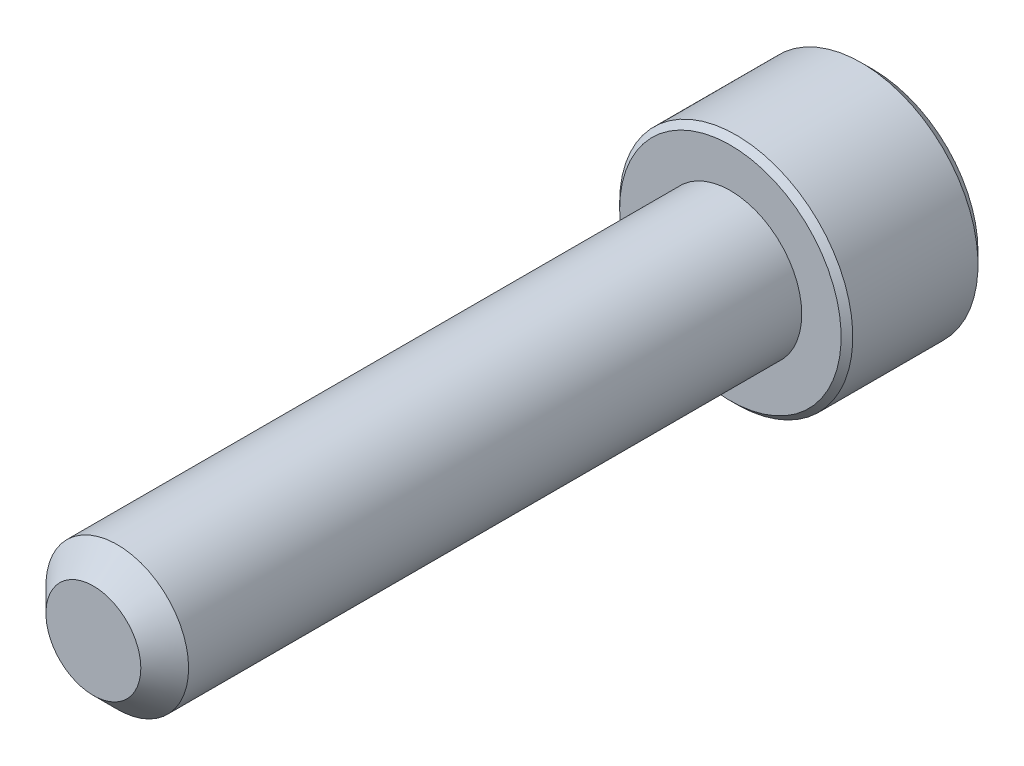
from build123d import *

# Parameters (mm, degrees)
SKETCH1_R          = 1.4224
EXTRUDE1_DEPTH     = 12.7
CHAMFER3_SIZE      = 0.47625
SKETCH6_R          = 2.3241
EXTRUDE2_DEPTH     = 2.8448
CUT_EXTRUDE1_DEPTH = 1.7859375
CHAMFER1_SIZE      = 0.23241
CHAMFER2_SIZE      = 0.116205


with BuildPart() as part:
    # Sketch1 → Extrude1 (new body)
    with BuildSketch(Plane.XY):
        Circle(SKETCH1_R)
    extrude(amount=-EXTRUDE1_DEPTH)

    # Chamfer3
    chamfer3_edges = [part.edges().sort_by_distance(p)[0] for p in [
        (-1.4224, 0, 0),
    ]]
    chamfer(chamfer3_edges, length=CHAMFER3_SIZE)

    # Sketch6 → Extrude2 (add)
    with BuildSketch(Plane(origin=(0, 0, -12.7), x_dir=(-1, 0, 0), z_dir=(0, 0, -1))):
        Circle(SKETCH6_R)
    extrude(amount=EXTRUDE2_DEPTH)

    # Sketch7 → Cut-Extrude1 (cut)
    with BuildSketch(Plane(origin=(0, 0, -15.5448), x_dir=(-1, 0, 0), z_dir=(0, 0, -1))):
        Polygon((0, 1.374815329), (-1.190625, 0.687407664), (-1.190625, -0.687407664), (0, -1.374815329), (1.190625, -0.687407664), (1.190625, 0.687407664), align=None)
    extrude(amount=-CUT_EXTRUDE1_DEPTH, mode=Mode.SUBTRACT)

    # Cut-Extrude2 cone 1 section (through the dimple's axis) → Cut-Extrude2 (revolve, cut)
    with BuildSketch(Plane(origin=(0, 0, -15.5448), x_dir=(0, 1, 0), z_dir=(1, 0, 0))):
        Polygon((0, 0), (1.374815329, 0), (0, 1.374815329), align=None)
    revolve(axis=Axis((0, 0, -15.5448), (0, 0, 1)), mode=Mode.SUBTRACT)

    # Chamfer1
    chamfer1_edges = [part.edges().sort_by_distance(p)[0] for p in [
        (2.3241, 0, -15.5448),
    ]]
    chamfer(chamfer1_edges, length=CHAMFER1_SIZE)

    # Chamfer2
    chamfer2_edges = [part.edges().sort_by_distance(p)[0] for p in [
        (2.3241, 0, -12.7),
    ]]
    chamfer(chamfer2_edges, length=CHAMFER2_SIZE)


solid = part.part
